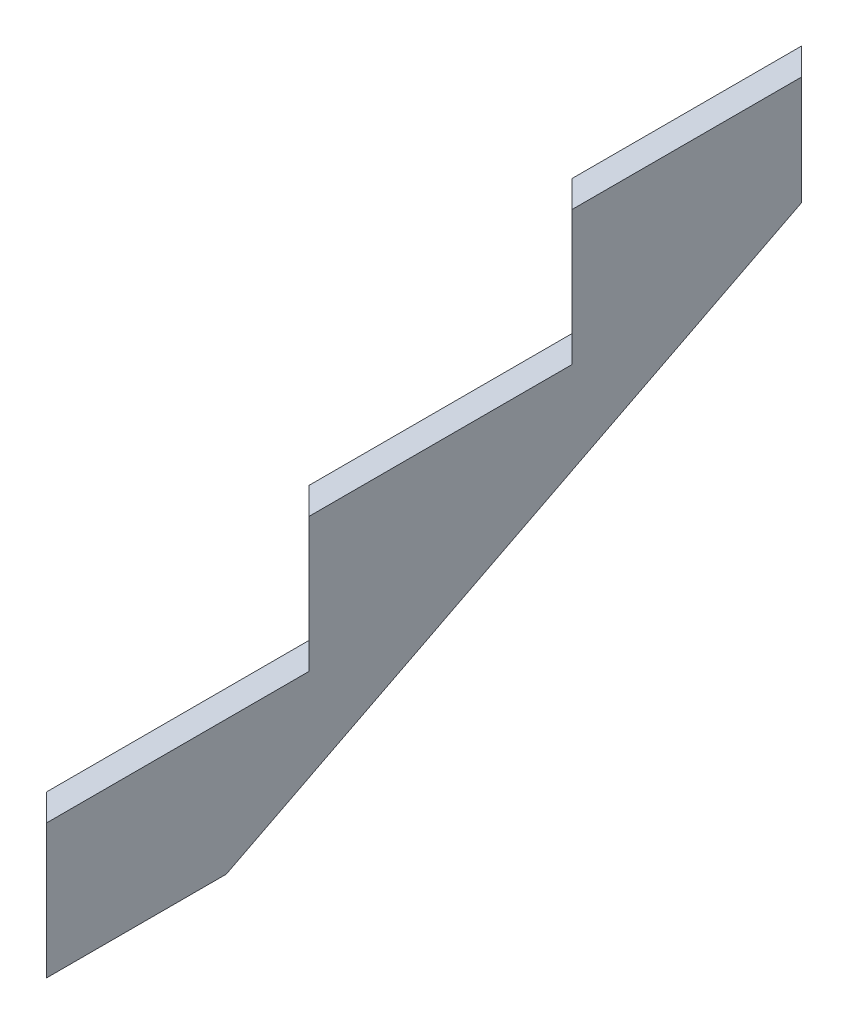
from build123d import *

# Parameters (mm, degrees)
BOSS_EXTRUDE2_DEPTH = 38.1
CUT_EXTRUDE2_REACH  = 573.5
CUT_EXTRUDE3_DEPTH  = 190.5
CUT_EXTRUDE4_DEPTH  = 190.5
CUT_EXTRUDE5_DEPTH  = 190.5


with BuildPart() as part:
    # Sketch1 → Boss-Extrude2 (new body)
    with BuildSketch(Plane(origin=(0, 0, 0), x_dir=(0, 0, -1), z_dir=(1, 0, 0))):
        Polygon((0, 0), (0, 190.5), (372.860234147, 190.5), (372.860234147, 381), (745.720468294, 381), (745.720468294, 571.5), (1109.600446319, 571.5), (1109.600446319, 436.526629402), (255.199284902, 0), align=None)
    extrude(amount=BOSS_EXTRUDE2_DEPTH)

    # Cut-Extrude2: up to this face of the body (flat: up to its plane)
    cut_extrude2_end = Plane(part.part.faces().sort_by_distance((19.05, 218.263314701, -682.399865611))[0])
    # Sketch2 → Cut-Extrude2 (cut, up to the picked face)
    with BuildSketch(Plane(origin=(0, 571.5, 0), x_dir=(1, 0, 0), z_dir=(0, 1, 0)), mode=Mode.PRIVATE) as cut_extrude2_sk1:
        Polygon((38.1, 1109.600446319), (0, 1109.600446319), (38.1, 1071.500446319), align=None)
    cut_extrude2_tool1 = split(extrude(cut_extrude2_sk1.sketch, amount=-CUT_EXTRUDE2_REACH, mode=Mode.PRIVATE), bisect_by=cut_extrude2_end, keep=Keep.BOTH, mode=Mode.PRIVATE)
    add(cut_extrude2_tool1.solids().sort_by_distance((25.4, 571.5, -1096.900446))[0], mode=Mode.SUBTRACT)

    # Sketch2_3 → Cut-Extrude3 (cut)
    with BuildSketch(Plane(origin=(0, 571.5, 0), x_dir=(1, 0, 0), z_dir=(0, 1, 0))):
        Polygon((38.1, 745.720468294), (0, 783.820468294), (0, 745.720468294), align=None)
    extrude(amount=-CUT_EXTRUDE3_DEPTH, mode=Mode.SUBTRACT)

    # Sketch3 → Cut-Extrude4 (cut)
    with BuildSketch(Plane(origin=(0, 381, 0), x_dir=(1, 0, 0), z_dir=(0, 1, 0))):
        Polygon((38.1, 372.860234147), (0, 410.960234147), (0, 372.860234147), align=None)
    extrude(amount=-CUT_EXTRUDE4_DEPTH, mode=Mode.SUBTRACT)

    # Sketch4 → Cut-Extrude5 (cut)
    with BuildSketch(Plane(origin=(0, 190.5, 0), x_dir=(1, 0, 0), z_dir=(0, 1, 0))):
        Polygon((38.1, 0), (0, 38.1), (0, 0), align=None)
    extrude(amount=-CUT_EXTRUDE5_DEPTH, mode=Mode.SUBTRACT)


solid = part.part
